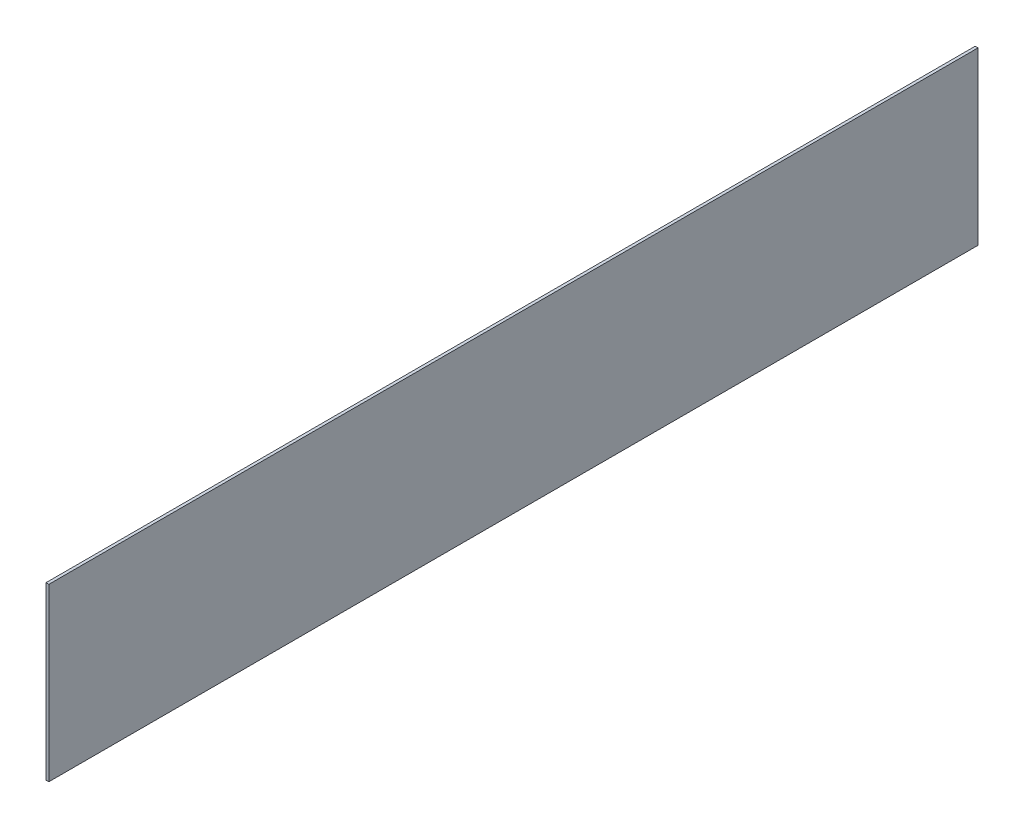
from build123d import *

# Parameters (mm, degrees)
SKETCH1_W           = 326
SKETCH1_H           = 60
BOSS_EXTRUDE1_DEPTH = 1


with BuildPart() as part:
    # Sketch1 → Boss-Extrude1 (new body)
    with BuildSketch(Plane(origin=(0, 0, 0), x_dir=(0, 0, -1), z_dir=(1, 0, 0))):
        with Locations((163, 30)):
            Rectangle(SKETCH1_W, SKETCH1_H)
    extrude(amount=BOSS_EXTRUDE1_DEPTH)


solid = part.part
